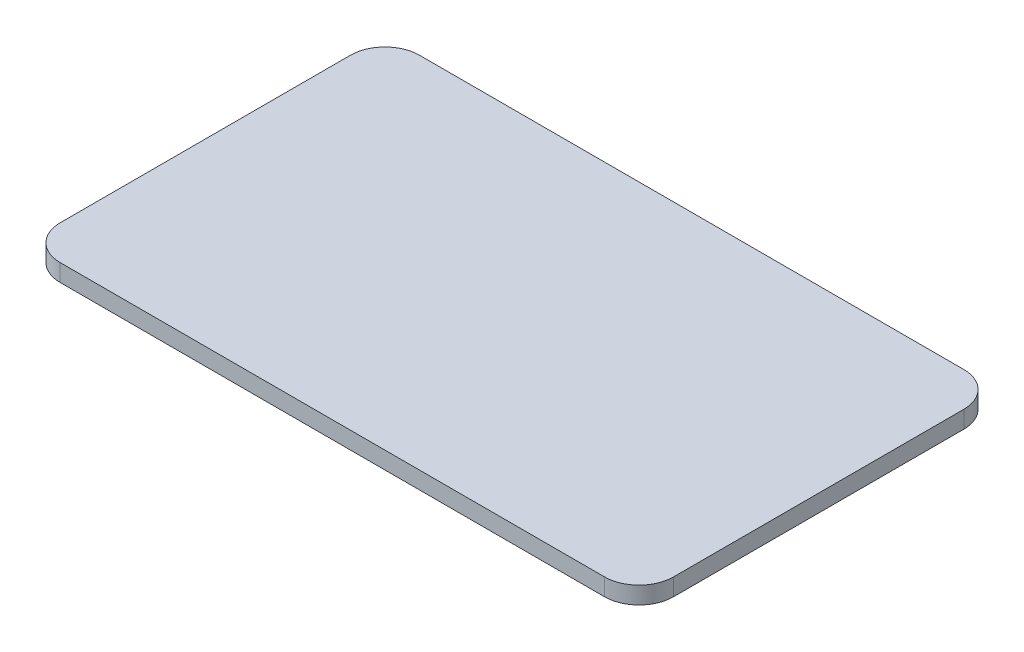
from build123d import *

# Parameters (mm, degrees)
BOSS_EXTRUDE1_DEPTH = 2.5


with BuildPart() as part:
    # Sketch1 → Boss-Extrude1 (new body)
    with BuildSketch(Plane(origin=(0, 0, 0), x_dir=(1, 0, 0), z_dir=(0, 1, 0))):
        with BuildLine():
            Line((-39.45, -26.035), (39.45, -26.035))
            ThreePointArc((39.45, -26.035), (42.985533906, -24.570533906), (44.45, -21.035))
            Line((44.45, -21.035), (44.45, 21.035))
            ThreePointArc((44.45, 21.035), (42.985533906, 24.570533906), (39.45, 26.035))
            Line((39.45, 26.035), (-39.45, 26.035))
            ThreePointArc((-39.45, 26.035), (-42.985533906, 24.570533906), (-44.45, 21.035))
            Line((-44.45, 21.035), (-44.45, -21.035))
            ThreePointArc((-44.45, -21.035), (-42.985533906, -24.570533906), (-39.45, -26.035))
        make_face()
    extrude(amount=BOSS_EXTRUDE1_DEPTH)


solid = part.part
